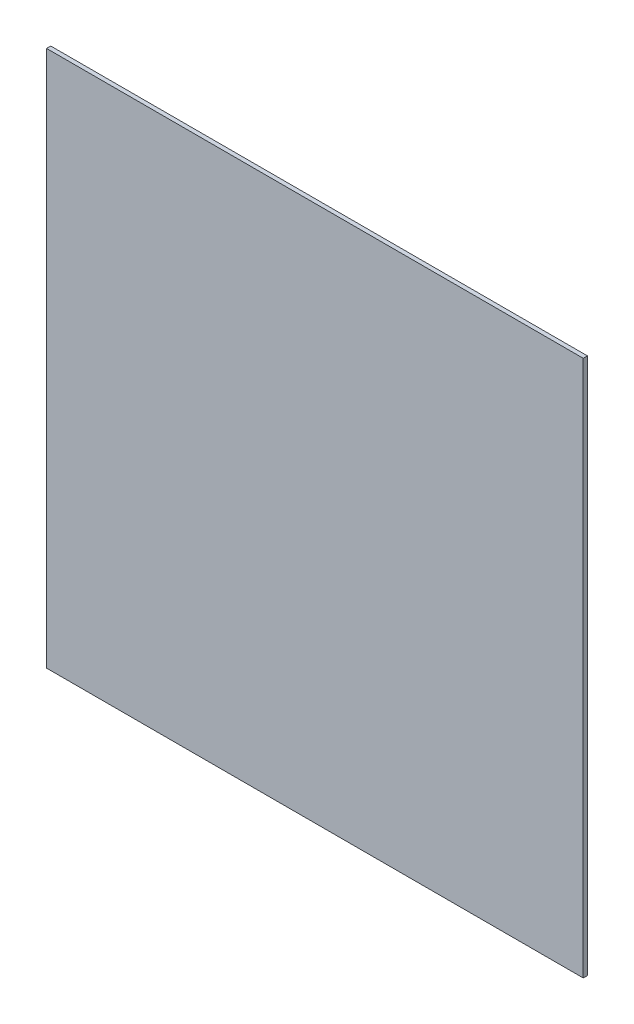
from build123d import *

# Parameters (mm, degrees)
SKETCH1_W    = 101.6
SKETCH1_H    = 101.6
PLAQUE_DEPTH = 0.79375


with BuildPart() as part:
    # Sketch1 → Plaque (new body)
    with BuildSketch(Plane.XY):
        with Locations((50.8, -50.8)):
            Rectangle(SKETCH1_W, SKETCH1_H)
    extrude(amount=PLAQUE_DEPTH)


solid = part.part
